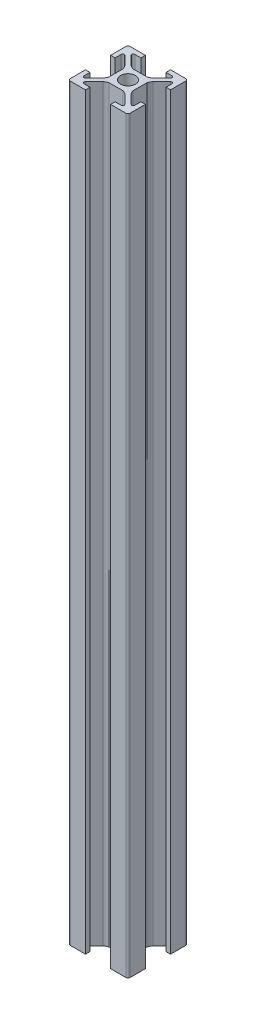
from build123d import *

# Parameters (mm, degrees)
SKETCH1_R           = 2.5
BOSS_EXTRUDE1_DEPTH = 250


with BuildPart() as part:
    # Sketch1 → Boss-Extrude1 (new body)
    with BuildSketch(Plane(origin=(0, 0, 0), x_dir=(1, 0, 0), z_dir=(0, 1, 0))):
        with BuildLine():
            Line((-3.610984523, 4.671644695), (-6.585786438, 7.646446609))
            ThreePointArc((-6.585786438, 7.646446609), (-6.694172813, 8.191341716), (-6.232233047, 8.5))
            Line((-6.232233047, 8.5), (-4.2, 8.5))
            Line((-4.2, 8.5), (-4.2, 10))
            Line((-4.2, 10), (-9.25, 10))
            ThreePointArc((-9.25, 10), (-9.780330086, 9.780330086), (-10, 9.25))
            Line((-10, 9.25), (-10, 4.2))
            Line((-10, 4.2), (-8.5, 4.2))
            Line((-8.5, 4.2), (-8.5, 6.232233047))
            ThreePointArc((-8.5, 6.232233047), (-8.191341716, 6.694172813), (-7.646446609, 6.585786438))
            Line((-7.646446609, 6.585786438), (-4.671644695, 3.610984523))
            ThreePointArc((-4.671644695, 3.610984523), (-4.244383234, 2.985253206), (-4, 2.268058063))
            Line((-4, 2.268058063), (-4, -2.268058063))
            ThreePointArc((-4, -2.268058063), (-4.244383234, -2.985253206), (-4.671644695, -3.610984523))
            Line((-4.671644695, -3.610984523), (-7.646446609, -6.585786438))
            ThreePointArc((-7.646446609, -6.585786438), (-8.191341716, -6.694172813), (-8.5, -6.232233047))
            Line((-8.5, -6.232233047), (-8.5, -4.2))
            Line((-8.5, -4.2), (-10, -4.2))
            Line((-10, -4.2), (-10, -9.25))
            ThreePointArc((-10, -9.25), (-9.780330086, -9.780330086), (-9.25, -10))
            Line((-9.25, -10), (-4.2, -10))
            Line((-4.2, -10), (-4.2, -8.5))
            Line((-4.2, -8.5), (-6.232233047, -8.5))
            ThreePointArc((-6.232233047, -8.5), (-6.694172813, -8.191341716), (-6.585786438, -7.646446609))
            Line((-6.585786438, -7.646446609), (-3.610984523, -4.671644695))
            ThreePointArc((-3.610984523, -4.671644695), (-2.985253206, -4.244383234), (-2.268058063, -4))
            Line((-2.268058063, -4), (2.268058063, -4))
            ThreePointArc((2.268058063, -4), (2.985253206, -4.244383234), (3.610984523, -4.671644695))
            Line((3.610984523, -4.671644695), (6.585786438, -7.646446609))
            ThreePointArc((6.585786438, -7.646446609), (6.694172813, -8.191341716), (6.232233047, -8.5))
            Line((6.232233047, -8.5), (4.2, -8.5))
            Line((4.2, -8.5), (4.2, -10))
            Line((4.2, -10), (9.25, -10))
            ThreePointArc((9.25, -10), (9.780330086, -9.780330086), (10, -9.25))
            Line((10, -9.25), (10, -4.2))
            Line((10, -4.2), (8.5, -4.2))
            Line((8.5, -4.2), (8.5, -6.232233047))
            ThreePointArc((8.5, -6.232233047), (8.191341716, -6.694172813), (7.646446609, -6.585786438))
            Line((7.646446609, -6.585786438), (4.671644695, -3.610984523))
            ThreePointArc((4.671644695, -3.610984523), (4.244383234, -2.985253206), (4, -2.268058063))
            Line((4, -2.268058063), (4, 2.268058063))
            ThreePointArc((4, 2.268058063), (4.244383234, 2.985253206), (4.671644695, 3.610984523))
            Line((4.671644695, 3.610984523), (7.646446609, 6.585786438))
            ThreePointArc((7.646446609, 6.585786438), (8.191341716, 6.694172813), (8.5, 6.232233047))
            Line((8.5, 6.232233047), (8.5, 4.2))
            Line((8.5, 4.2), (10, 4.2))
            Line((10, 4.2), (10, 9.25))
            ThreePointArc((10, 9.25), (9.780330086, 9.780330086), (9.25, 10))
            Line((9.25, 10), (4.2, 10))
            Line((4.2, 10), (4.2, 8.5))
            Line((4.2, 8.5), (6.232233047, 8.5))
            ThreePointArc((6.232233047, 8.5), (6.694172813, 8.191341716), (6.585786438, 7.646446609))
            Line((6.585786438, 7.646446609), (3.610984523, 4.671644695))
            ThreePointArc((3.610984523, 4.671644695), (2.985253206, 4.244383234), (2.268058063, 4))
            Line((2.268058063, 4), (-2.268058063, 4))
            ThreePointArc((-2.268058063, 4), (-2.985253206, 4.244383234), (-3.610984523, 4.671644695))
        make_face()
        Circle(SKETCH1_R, mode=Mode.SUBTRACT)
    extrude(amount=BOSS_EXTRUDE1_DEPTH)


solid = part.part
